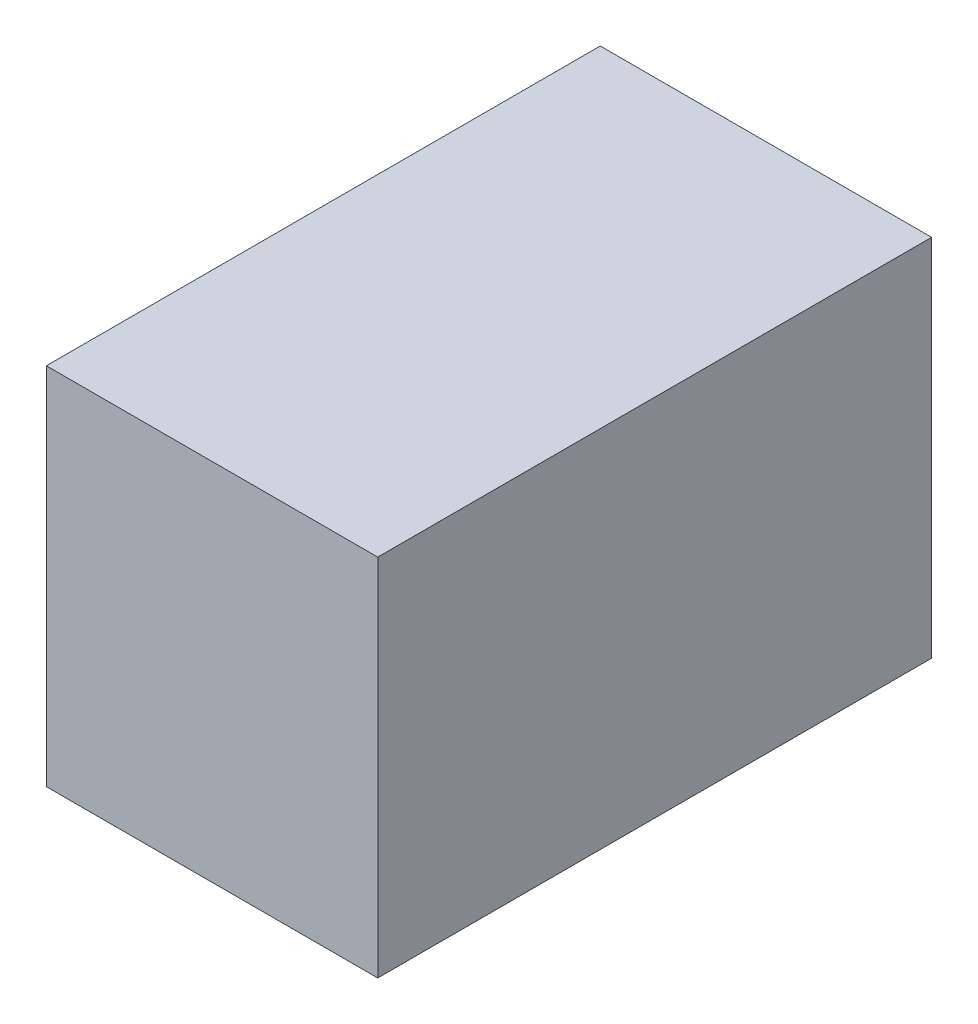
from build123d import *

# Parameters (mm, degrees)
SKETCH4_W           = 31.1
SKETCH4_H           = 19.1
BOSS_EXTRUDE1_DEPTH = 19
SHELL1_T            = 2
SKETCH5_W           = 12
SKETCH5_H           = 19.1
CUT_EXTRUDE1_DEPTH  = 2


with BuildPart() as part:
    # Sketch4 → Boss-Extrude1 (new body)
    with BuildSketch(Plane(origin=(0, 0, 0), x_dir=(0, 0, -1), z_dir=(1, 0, 0))):
        Rectangle(SKETCH4_W, SKETCH4_H)
    extrude(amount=BOSS_EXTRUDE1_DEPTH)

    # Shell1
    shell1_openings = [part.faces().sort_by_distance(p)[0] for p in [
        (0, 0, 0),
    ]]
    offset(amount=SHELL1_T, openings=shell1_openings, kind=Kind.INTERSECTION)

    # Sketch5 → Cut-Extrude1 (cut)
    with BuildSketch(Plane(origin=(0, 0, -17.55), x_dir=(-1, 0, 0), z_dir=(0, 0, -1))):
        with Locations((-6, 0)):
            Rectangle(SKETCH5_W, SKETCH5_H)
    extrude(amount=-CUT_EXTRUDE1_DEPTH, mode=Mode.SUBTRACT)


solid = part.part
